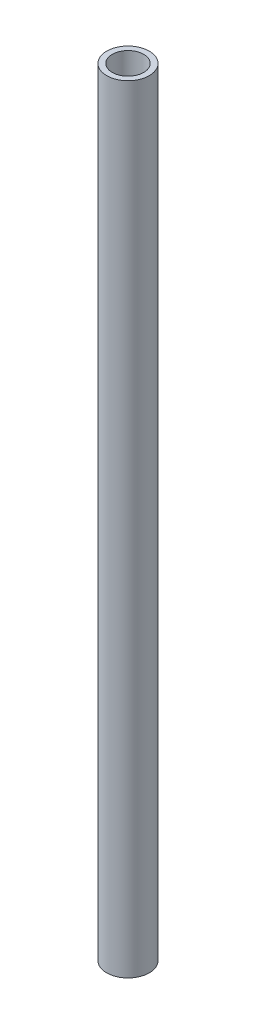
from build123d import *

# Parameters (mm, degrees)
CROQUIS1_R              = 11.5
CROQUIS1_R_2            = 8.5
SALIENTE_EXTRUIR1_DEPTH = 210


with BuildPart() as part:
    # Croquis1 → Saliente-Extruir1 (new body, symmetric)
    with BuildSketch(Plane(origin=(0, 0, 0), x_dir=(1, 0, 0), z_dir=(0, 1, 0))):
        Circle(CROQUIS1_R)
        Circle(CROQUIS1_R_2, mode=Mode.SUBTRACT)
    extrude(amount=SALIENTE_EXTRUIR1_DEPTH, both=True)


solid = part.part
